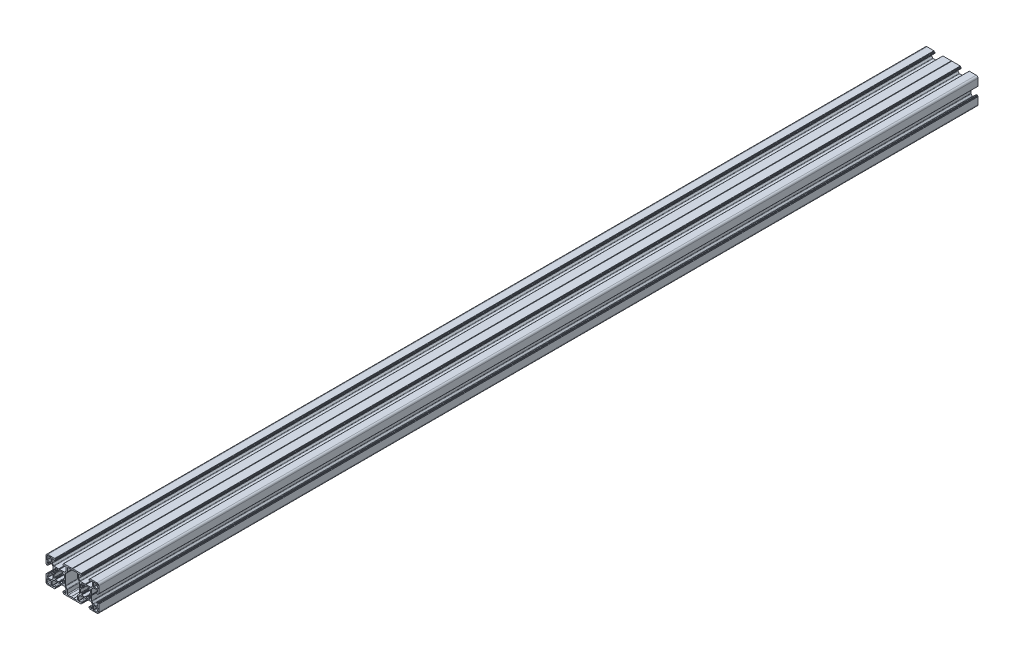
from build123d import *

# Parameters (mm, degrees)
EXTRUDE_1_DEPTH     = 1000
CUT_EXTRUDE_5_DEPTH = 1001
SKETCH_5_W          = 4.9
SKETCH_5_H          = 0.8
CUT_EXTRUDE_1_DEPTH = 1001
CUT_EXTRUDE_3_DEPTH = 1000
CUT_EXTRUDE_6_DEPTH = 1001
CUT_EXTRUDE_7_DEPTH = 1001
FILLET_10_R         = 0.25
FILLET_7_R          = 0.75
FILLET_16_R         = 0.25
FILLET_21_R         = 0.25
FILLET_24_R         = 0.25
FILLET_6_R          = 2
FILLET_22_R         = 1
FILLET_23_R         = 0.4
CUT_EXTRUDE_8_DEPTH = 1001
EXTRUDE_5_DEPTH     = 1000
CUT_EXTRUDE_4_DEPTH = 1000
EXTRUDE_6_DEPTH     = 1000
FILLET_18_R         = 1
FILLET_19_R         = 0.25
FILLET_25_R         = 1


with BuildPart() as part:
    # Sketch 3 → Extrude 1 (new body)
    with BuildSketch(Plane.XY):
        with BuildLine():
            Line((-15, 15), (-4.1, 15))
            Line((-4.1, 15), (-4.1, 12.8))
            Line((-4.1, 12.8), (-8, 12.8))
            Line((-8, 12.8), (-8, 8.883883476))
            Line((-8, 8.883883476), (-6.116116524, 7))
            Line((-6.116116524, 7), (0, 7))
            Line((0, 7), (0, 5))
            ThreePointArc((0, 5), (-1.913417162, 4.619397663), (-3.535533906, 3.535533906))
            Line((-3.535533906, 3.535533906), (-15, 15))
        make_face()
    extrude(amount=-EXTRUDE_1_DEPTH)

    # Sketch 17 → Cut-Extrude 5 (cut, through all)
    with BuildSketch(Plane.XY):
        with BuildLine():
            Line((-9.1, 13.9), (-9.1, 12.5))
            ThreePointArc((-9.1, 12.5), (-9.2, 11.5), (-9.1, 10.5))
            Line((-9.1, 10.5), (-9.1, 9.1))
            Line((-9.1, 9.1), (-13.9, 9.1))
            Line((-13.9, 9.1), (-13.9, 13.9))
            Line((-13.9, 13.9), (-12.5, 13.9))
            ThreePointArc((-12.5, 13.9), (-11.5, 13.8), (-10.5, 13.9))
            Line((-10.5, 13.9), (-9.1, 13.9))
        make_face()
    extrude(amount=-CUT_EXTRUDE_5_DEPTH, mode=Mode.SUBTRACT)

    # Sketch 5 → Cut-Extrude 1 (cut, through all)
    with BuildSketch(Plane.XY):
        with Locations((-2.45, 14.6)):
            Rectangle(SKETCH_5_W, SKETCH_5_H)
    extrude(amount=-CUT_EXTRUDE_1_DEPTH, mode=Mode.SUBTRACT)

    # Sketch 11 → Cut-Extrude 3 (cut)
    with BuildSketch(Plane.XY):
        Polygon((0, 7), (-0.45, 7), (0, 6.7), align=None)
    extrude(amount=-CUT_EXTRUDE_3_DEPTH, mode=Mode.SUBTRACT)

    # Sketch 18 → Cut-Extrude 6 (cut, through all)
    with BuildSketch(Plane.XY):
        Polygon((-8, 12.8), (-8, 13.4), (-6.1, 13.4), (-5.7, 12.8), align=None)
    extrude(amount=-CUT_EXTRUDE_6_DEPTH, mode=Mode.SUBTRACT)

    # Sketch 19 → Cut-Extrude 7 (cut, through all)
    with BuildSketch(Plane.XY):
        with BuildLine():
            Line((-3.202987828, 3.839383931), (-4.810050506, 5.8))
            Line((-4.810050506, 5.8), (-0.6, 5.8))
            Line((-0.6, 5.8), (-0.45, 4.979708827))
            ThreePointArc((-0.45, 4.979708827), (-1.913417162, 4.619397663), (-3.202987828, 3.839383931))
        make_face()
    extrude(amount=-CUT_EXTRUDE_7_DEPTH, mode=Mode.SUBTRACT)

    # Fillet 10
    fillet_10_edges = [part.edges().sort_by_distance(p)[0] for p in [
        (-4.1, 12.8, -500),
    ]]
    fillet(fillet_10_edges, radius=FILLET_10_R)

    # Fillet 7
    fillet_7_edges = [part.edges().sort_by_distance(p)[0] for p in [
        (-8, 8.883883476, -500),
        (-6.116116524, 7, -500),
    ]]
    fillet(fillet_7_edges, radius=FILLET_7_R)

    # Fillet 16
    fillet_16_edges = [part.edges().sort_by_distance(p)[0] for p in [
        (-4.1, 14.2, -500),
        (-4.9, 15, -500),
        (-0.45, 7, -500),
    ]]
    fillet(fillet_16_edges, radius=FILLET_16_R)

    # Fillet 21
    fillet_21_edges = [part.edges().sort_by_distance(p)[0] for p in [
        (-9.1, 13.9, -500),
        (-5.7, 12.8, -500),
        (-8, 13.4, -500),
        (-6.1, 13.4, -500),
    ]]
    fillet(fillet_21_edges, radius=FILLET_21_R)

    # Fillet 24
    fillet_24_edges = [part.edges().sort_by_distance(p)[0] for p in [
        (-4.810050506, 5.8, -500),
        (-0.6, 5.8, -500),
        (-0.45, 4.979708827, -500),
        (-3.202987828, 3.839383931, -500),
    ]]
    fillet(fillet_24_edges, radius=FILLET_24_R)

    # Mirror 21: part across plane


with BuildPart() as part_1:
    add(part.part)
    add(part.part.mirror(Plane(origin=(-3.535533906, 3.535533906, -1000), x_dir=(0, 0, 1), z_dir=(-0.707106781, -0.707106781, 0))))

    # Fillet 6
    fillet_6_edges = [part_1.edges().sort_by_distance(p)[0] for p in [
        (-15, 15, -500),
    ]]
    fillet(fillet_6_edges, radius=FILLET_6_R)

    # Fillet 22
    fillet_22_edges = [part_1.edges().sort_by_distance(p)[0] for p in [
        (-13.9, 13.9, -500),
    ]]
    fillet(fillet_22_edges, radius=FILLET_22_R)

    # Fillet 23
    fillet_23_edges = [part_1.edges().sort_by_distance(p)[0] for p in [
        (-9.1, 9.1, -500),
    ]]
    fillet(fillet_23_edges, radius=FILLET_23_R)

    # Mirror 24: part across plane


with BuildPart() as part_2:
    add(part_1.part)
    add(part_1.part.mirror(Plane(origin=(0, 7, -1000), x_dir=(0, 0, 1), z_dir=(1, 0, 0))))

    # Sketch 20 → Cut-Extrude 8 (cut, through all)
    with BuildSketch(Plane.XY):
        Polygon((7, 6.186827202), (9.1, 8.286827202), (9.1, 15), (15, 15), (15, 0), (7, 0), align=None)
    extrude(amount=-CUT_EXTRUDE_8_DEPTH, mode=Mode.SUBTRACT)

    # Sketch 13 → Extrude 5 (add)
    with BuildSketch(Plane.XY):
        Polygon((5.8, 0), (5.8, 6.683883476), (8, 8.883883476), (8, 15), (15, 15), (15, 13.65), (9.2, 13.65), (9.2, 8.386827202), (7, 6.186827202), (7, 0), align=None)
    extrude(amount=-EXTRUDE_5_DEPTH)

    # Sketch 15 → Cut-Extrude 4 (cut)
    with BuildSketch(Plane.XY):
        Polygon((15, 15), (14.75, 15), (15, 14.8), align=None)
    extrude(amount=-CUT_EXTRUDE_4_DEPTH, mode=Mode.SUBTRACT)

    # Sketch 16 → Extrude 6 (add)
    with BuildSketch(Plane.XY):
        with BuildLine():
            Line((15, 13.65), (13.480131585, 13.65))
            ThreePointArc((13.480131585, 13.65), (14.225403331, 13.425716626), (15, 13.35))
            Line((15, 13.35), (15, 13.65))
        make_face()
    extrude(amount=-EXTRUDE_6_DEPTH)

    # Fillet 18
    fillet_18_edges = [part_2.edges().sort_by_distance(p)[0] for p in [
        (9.2, 8.386827202, -500),
        (9.2, 13.65, -500),
    ]]
    fillet(fillet_18_edges, radius=FILLET_18_R)

    # Fillet 19
    fillet_19_edges = [part_2.edges().sort_by_distance(p)[0] for p in [
        (14.75, 15, -500),
    ]]
    fillet(fillet_19_edges, radius=FILLET_19_R)

    # Fillet 25
    fillet_25_edges = [part_2.edges().sort_by_distance(p)[0] for p in [
        (7, 6.186827202, -500),
    ]]
    fillet(fillet_25_edges, radius=FILLET_25_R)

    # Mirror 22: part across plane


with BuildPart() as part_3:
    add(part_2.part)
    add(part_2.part.mirror(Plane(origin=(15, 15, -1017.596590579), x_dir=(0, 0, 1), z_dir=(1, 0, 0))))

    # Mirror 23: part across plane


with BuildPart() as part_4:
    add(part_3.part)
    add(part_3.part.mirror(Plane(origin=(7, 0, -1000), x_dir=(0, 0, 1), z_dir=(0, -1, 0))))


solid = part_4.part
